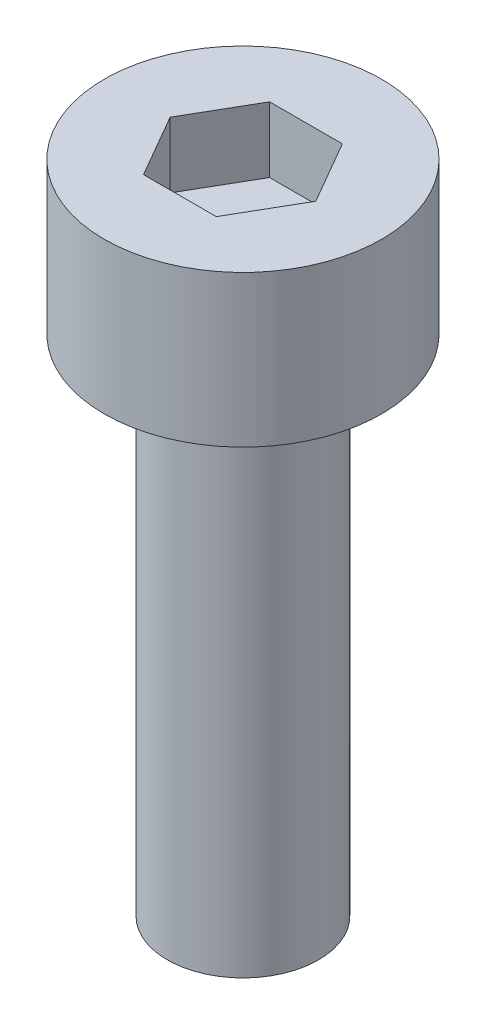
from build123d import *

# Parameters (mm, degrees)
SKETCH_1_R            = 2.75
EXTRUDE_248_DEPTH     = 3
CUT_EXTRUDE_378_DEPTH = 1.3
SKETCH_3_R            = 1.5
EXTRUDE_479_DEPTH     = 10


with BuildPart() as part:
    # 草图1 → Extrude 248 (new body)
    with BuildSketch(Plane(origin=(0, 0, 0), x_dir=(1, 0, 0), z_dir=(0, 1, 0))):
        Circle(SKETCH_1_R)
    extrude(amount=EXTRUDE_248_DEPTH)

    # 草图2 → Cut-Extrude 378 (cut)
    with BuildSketch(Plane(origin=(0, 3, 0), x_dir=(1, 0, 0), z_dir=(0, 1, 0))):
        Polygon((1.443375673, 0), (0.721687836, 1.25), (-0.721687836, 1.25), (-1.443375673, 0), (-0.721687836, -1.25), (0.721687836, -1.25), align=None)
    extrude(amount=-CUT_EXTRUDE_378_DEPTH, mode=Mode.SUBTRACT)

    # 草图3 → Extrude 479 (add)
    with BuildSketch(Plane.XZ):
        Circle(SKETCH_3_R)
    extrude(amount=EXTRUDE_479_DEPTH)


solid = part.part
